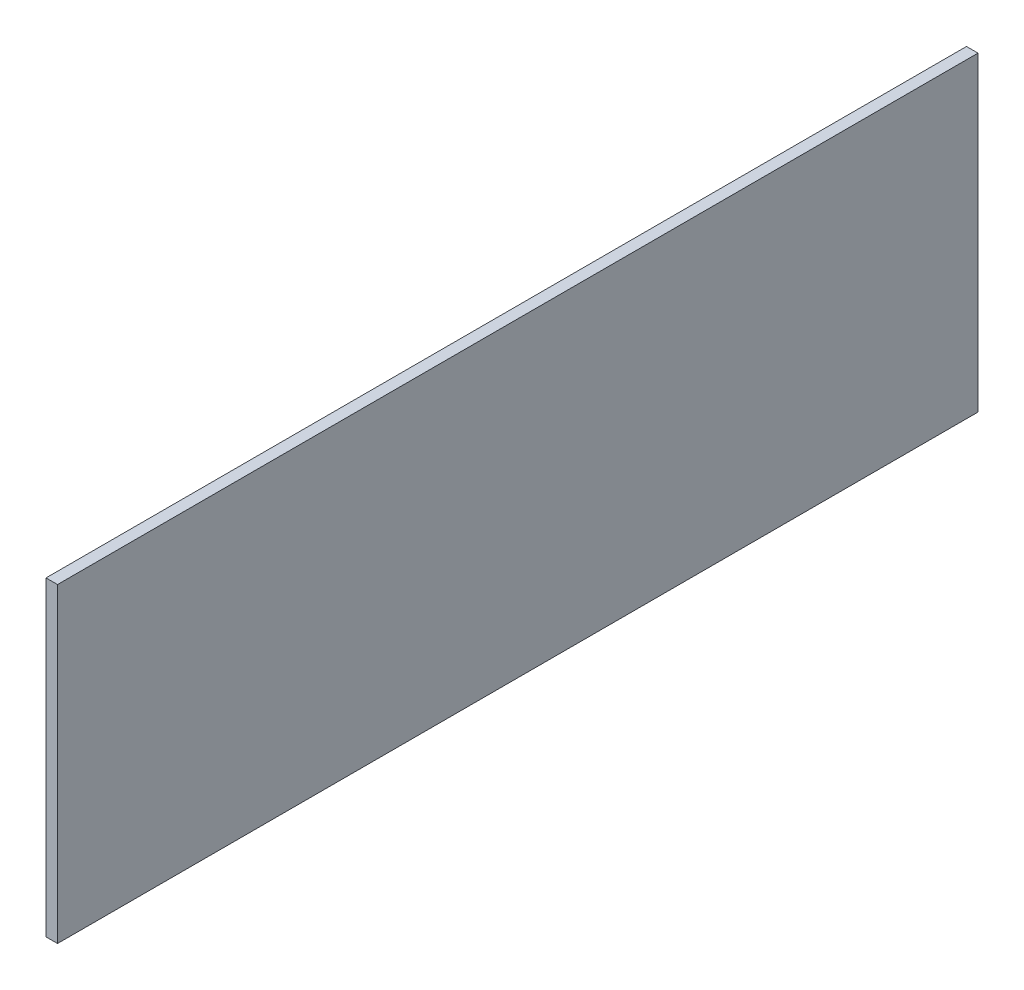
from build123d import *

# Parameters (mm, degrees)
SKETCH1_W           = 1016
SKETCH1_H           = 343.154
BOSS_EXTRUDE1_DEPTH = 12.7


with BuildPart() as part:
    # Sketch1 → Boss-Extrude1 (new body)
    with BuildSketch(Plane(origin=(0, 0, 0), x_dir=(0, 0, -1), z_dir=(1, 0, 0))):
        Rectangle(SKETCH1_W, SKETCH1_H)
    extrude(amount=BOSS_EXTRUDE1_DEPTH)


solid = part.part
